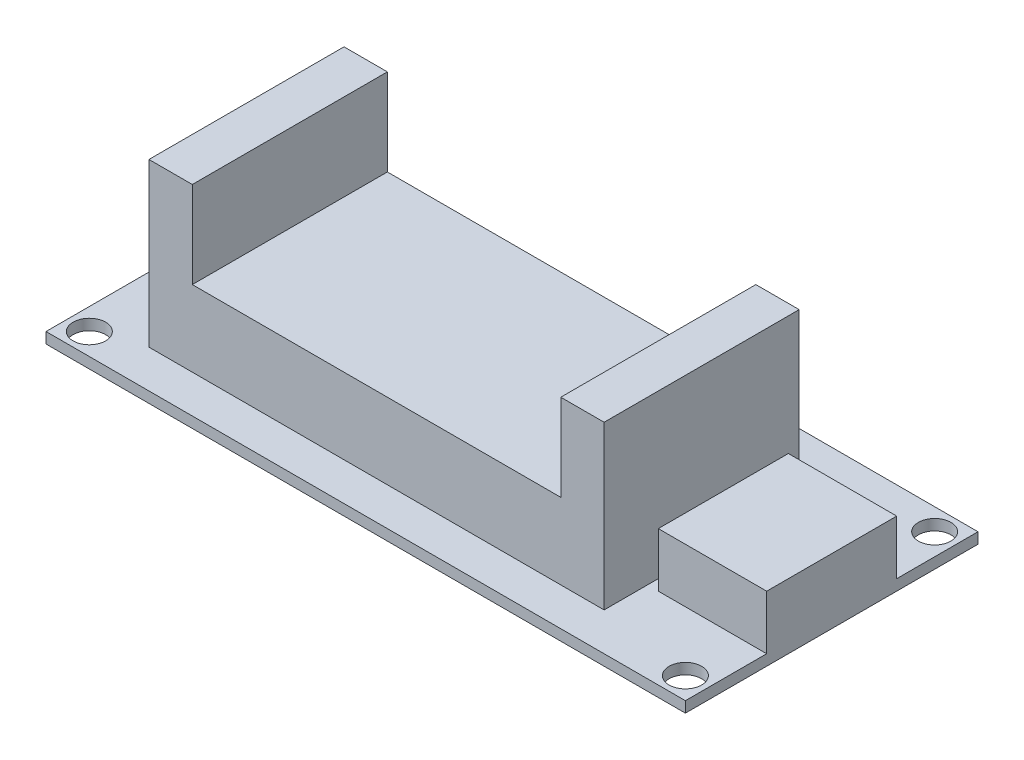
from build123d import *

# Parameters (mm, degrees)
SKETCH1_W           = 59
SKETCH1_H           = 27
SKETCH1_R           = 1.5
BOSS_EXTRUDE1_DEPTH = 1
SKETCH2_W           = 34
SKETCH2_H           = 18
BOSS_EXTRUDE2_DEPTH = 7
SKETCH3_W           = 4
SKETCH3_H           = 18
BOSS_EXTRUDE3_DEPTH = 15
SKETCH4_W           = 4
SKETCH4_H           = 18
BOSS_EXTRUDE4_DEPTH = 15
SKETCH7_W           = 10
SKETCH7_H           = 12
BOSS_EXTRUDE7_DEPTH = 5
SKETCH8_W           = 6
SKETCH8_H           = 6.85
BOSS_EXTRUDE8_DEPTH = 1.8


with BuildPart() as part:
    # Sketch1 → Boss-Extrude1 (new body)
    with BuildSketch(Plane(origin=(0, 0, 0), x_dir=(1, 0, 0), z_dir=(0, 1, 0))):
        with Locations((1.308219178, 7.805712308)):
            Rectangle(SKETCH1_W, SKETCH1_H)
        with Locations((-26.191780822, -3.694287692)):
            Circle(SKETCH1_R, mode=Mode.SUBTRACT)
        with Locations((-26.191780822, 19.305712308)):
            Circle(SKETCH1_R, mode=Mode.SUBTRACT)
        with Locations((28.808219178, 19.305712308)):
            Circle(SKETCH1_R, mode=Mode.SUBTRACT)
        with Locations((28.808219178, -3.694287692)):
            Circle(SKETCH1_R, mode=Mode.SUBTRACT)
    extrude(amount=BOSS_EXTRUDE1_DEPTH)

    # Sketch2 → Boss-Extrude2 (add)
    with BuildSketch(Plane(origin=(0, 1, 0), x_dir=(1, 0, 0), z_dir=(0, 1, 0))):
        with Locations((-1.191780822, 6.805712308)):
            Rectangle(SKETCH2_W, SKETCH2_H)
    extrude(amount=BOSS_EXTRUDE2_DEPTH)

    # Sketch3 → Boss-Extrude3 (add)
    with BuildSketch(Plane(origin=(0, 1, 0), x_dir=(1, 0, 0), z_dir=(0, 1, 0))):
        with Locations((-20.191780822, 6.805712308)):
            Rectangle(SKETCH3_W, SKETCH3_H)
    extrude(amount=BOSS_EXTRUDE3_DEPTH)

    # Sketch4 → Boss-Extrude4 (add)
    with BuildSketch(Plane(origin=(0, 1, 0), x_dir=(1, 0, 0), z_dir=(0, 1, 0))):
        with Locations((17.808219178, 6.805712308)):
            Rectangle(SKETCH4_W, SKETCH4_H)
    extrude(amount=BOSS_EXTRUDE4_DEPTH)

    # Sketch7 → Boss-Extrude7 (add)
    with BuildSketch(Plane(origin=(0, 1, 0), x_dir=(1, 0, 0), z_dir=(0, 1, 0))):
        with Locations((25.808219178, 7.805712308)):
            Rectangle(SKETCH7_W, SKETCH7_H)
    extrude(amount=BOSS_EXTRUDE7_DEPTH)

    # Sketch8 → Boss-Extrude8 (add)
    with BuildSketch(Plane(origin=(0, 1, 0), x_dir=(1, 0, 0), z_dir=(0, 1, 0))):
        with Locations((-25.191780822, 7.805712308)):
            Rectangle(SKETCH8_W, SKETCH8_H)
    extrude(amount=BOSS_EXTRUDE8_DEPTH)


solid = part.part
